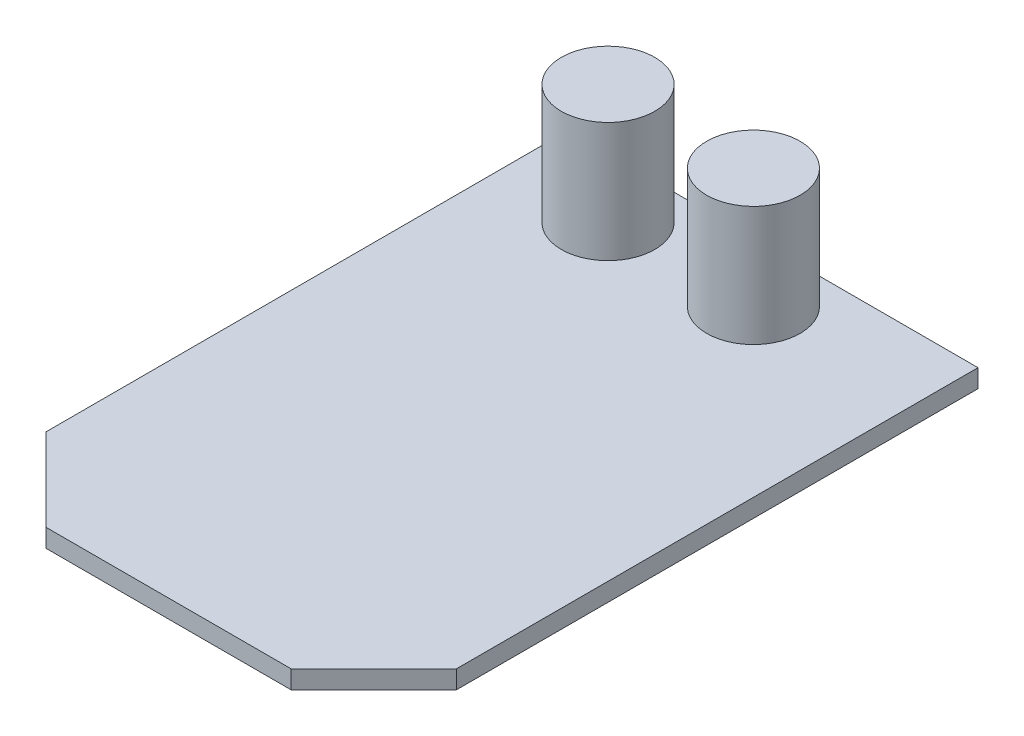
from build123d import *

# Parameters (mm, degrees)
BOSS_EXTRUDE1_DEPTH = 1.6
SKETCH2_W           = 30
SKETCH2_H           = 5
BOSS_EXTRUDE2_DEPTH = 1.15
SKETCH3_R           = 4.1
BOSS_EXTRUDE3_DEPTH = 10.5


with BuildPart() as part:
    # Sketch1 → Boss-Extrude1 (new body)
    with BuildSketch(Plane(origin=(0, 0, 0), x_dir=(1, 0, 0), z_dir=(0, 1, 0))):
        Polygon((-18, 26.5), (-18, -19.25), (-10.75, -26.5), (10.75, -26.5), (18, -19.25), (18, 26.5), align=None)
    extrude(amount=BOSS_EXTRUDE1_DEPTH)

    # Sketch2 → Boss-Extrude2 (add)
    with BuildSketch(Plane.XZ):
        with Locations((0, -14.7)):
            Rectangle(SKETCH2_W, SKETCH2_H)
    extrude(amount=BOSS_EXTRUDE2_DEPTH)

    # Sketch3 → Boss-Extrude3 (add)
    with BuildSketch(Plane(origin=(0, 1.6, 0), x_dir=(1, 0, 0), z_dir=(0, 1, 0))):
        with Locations((-9.25, 21.3)):
            Circle(SKETCH3_R)
        with Locations((3.5, 21.3)):
            Circle(SKETCH3_R)
    extrude(amount=BOSS_EXTRUDE3_DEPTH)


solid = part.part
